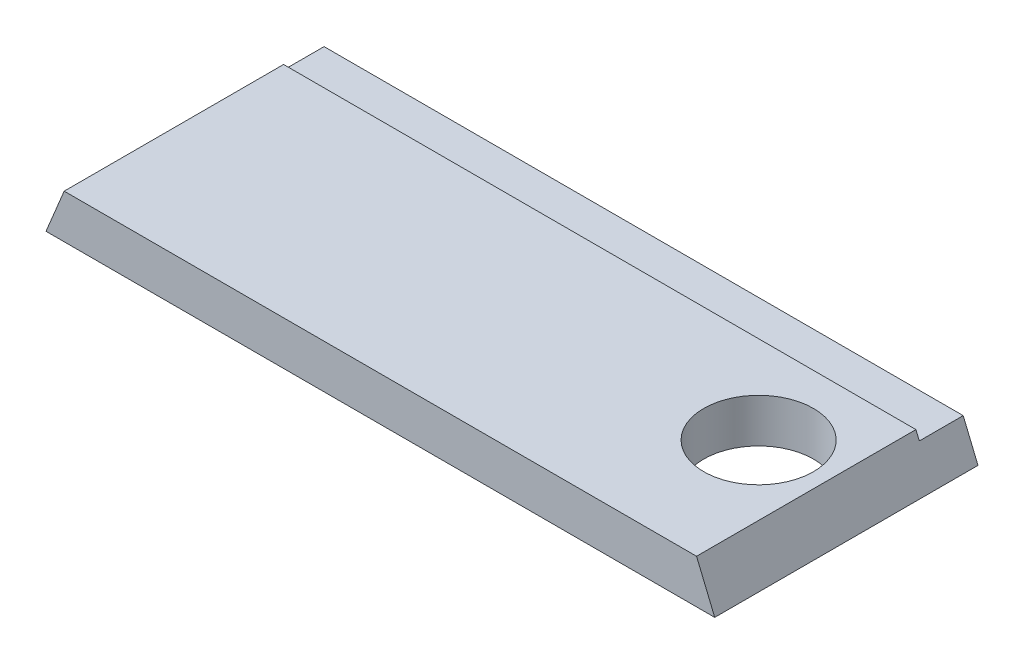
from build123d import *

# Parameters (mm, degrees)
BOSS_EXTRUDE1_DEPTH = 76.2
SKETCH2_W           = 193.548
SKETCH2_H           = 12.7
CUT_EXTRUDE1_DEPTH  = 2.3622
SKETCH3_R           = 15.875
CUT_EXTRUDE2_DEPTH  = 13.7


with BuildPart() as part:
    # Sketch1 → Boss-Extrude1 (new body)
    with BuildSketch(Plane.XY):
        Polygon((0, 0), (193.548, 0), (188.287487758, 12.7), (5.260512242, 12.7), align=None)
    extrude(amount=BOSS_EXTRUDE1_DEPTH)

    # Sketch2 → Cut-Extrude1 (cut)
    with BuildSketch(Plane(origin=(0, 12.7, 0), x_dir=(1, 0, 0), z_dir=(0, 1, 0))):
        with Locations((96.774, -6.35)):
            Rectangle(SKETCH2_W, SKETCH2_H)
    extrude(amount=-CUT_EXTRUDE1_DEPTH, mode=Mode.SUBTRACT)

    # Sketch3 → Cut-Extrude2 (cut, through all)
    with BuildSketch(Plane.XZ):
        with Locations((168.148, 38.1)):
            Circle(SKETCH3_R)
    extrude(amount=-CUT_EXTRUDE2_DEPTH, mode=Mode.SUBTRACT)


solid = part.part
